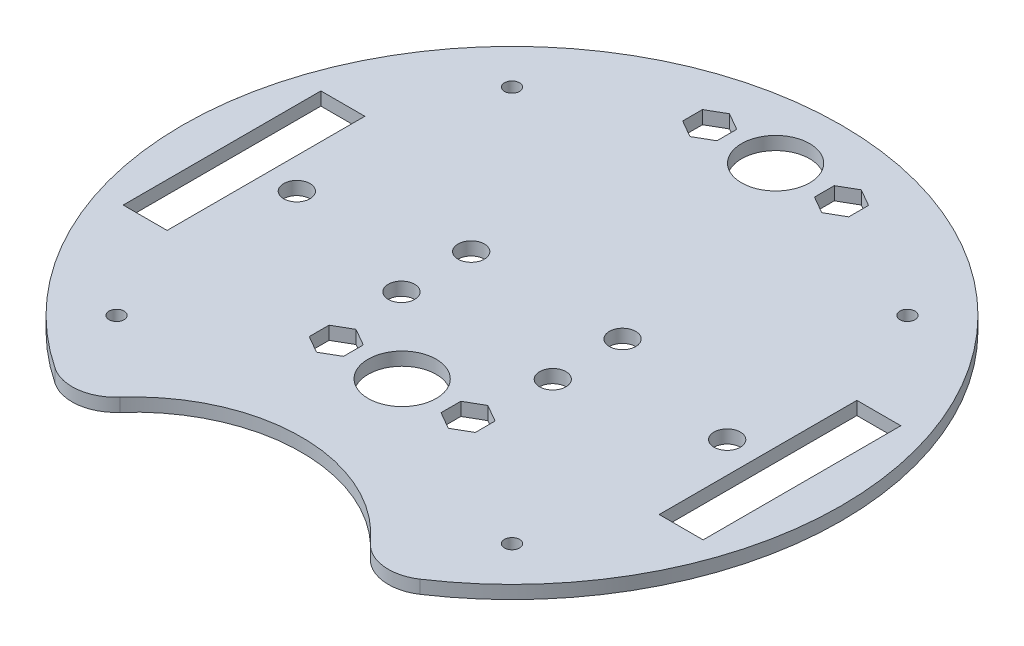
from build123d import *

# Parameters (mm, degrees)
SKETCH1_R           = 75
BOSS_EXTRUDE1_DEPTH = 3
SKETCH2_W           = 10
SKETCH2_H           = 45
CUT_EXTRUDE1_DEPTH  = 6.35
SKETCH3_R           = 7.75
CUT_EXTRUDE2_DEPTH  = 10
CUT_EXTRUDE3_DEPTH  = 10
FILLET2_R           = 10
SKETCH7_R           = 3
CUT_EXTRUDE5_DEPTH  = 3
CUT_EXTRUDE6_DEPTH  = 3
SKETCH8_R           = 1.7145
CUT_EXTRUDE7_DEPTH  = 10


with BuildPart() as part:
    # Sketch1 → Boss-Extrude1 (new body)
    with BuildSketch(Plane(origin=(0, 0, 0), x_dir=(1, 0, 0), z_dir=(0, 1, 0))):
        Circle(SKETCH1_R)
    extrude(amount=BOSS_EXTRUDE1_DEPTH)

    # Sketch2 → Cut-Extrude1 (cut)
    with BuildSketch(Plane(origin=(0, 3, 0), x_dir=(1, 0, 0), z_dir=(0, 1, 0))):
        with Locations((-61, 0)):
            Rectangle(SKETCH2_W, SKETCH2_H)
        with Locations((61, 0)):
            Rectangle(SKETCH2_W, SKETCH2_H)
    extrude(amount=-CUT_EXTRUDE1_DEPTH, mode=Mode.SUBTRACT)

    # Sketch3 → Cut-Extrude2 (cut)
    with BuildSketch(Plane(origin=(0, 3, 0), x_dir=(1, 0, 0), z_dir=(0, 1, 0))):
        with Locations((0, -25)):
            Circle(SKETCH3_R)
        with Locations((0, 60)):
            Circle(SKETCH3_R)
    extrude(amount=-CUT_EXTRUDE2_DEPTH, mode=Mode.SUBTRACT)

    # Sketch4 → Cut-Extrude3 (cut)
    with BuildSketch(Plane(origin=(0, 3, 0), x_dir=(1, 0, 0), z_dir=(0, 1, 0))):
        with BuildLine():
            ThreePointArc((-33.160552015, -67.270928268), (0, -47.932265908), (33.160552015, -67.270928268))
            ThreePointArc((33.160552015, -67.270928268), (0, -75), (-33.160552015, -67.270928268))
        make_face()
    extrude(amount=-CUT_EXTRUDE3_DEPTH, mode=Mode.SUBTRACT)

    # Fillet2
    fillet2_edges = [part.edges().sort_by_distance(p)[0] for p in [
        (-33.160552015, 1.5, 67.270928268),
        (33.160552015, 1.5, 67.270928268),
    ]]
    fillet(fillet2_edges, radius=FILLET2_R)

    # Sketch7 → Cut-Extrude5 (cut)
    with BuildSketch(Plane(origin=(0, 3, 0), x_dir=(1, 0, 0), z_dir=(0, 1, 0))):
        with Locations((-48.975, 0)):
            Circle(SKETCH7_R)
        with Locations((-17.225, -7.9375)):
            Circle(SKETCH7_R)
        with Locations((-17.225, 7.9375)):
            Circle(SKETCH7_R)
        with Locations((17.225, 7.9375)):
            Circle(SKETCH7_R)
        with Locations((17.225, -7.9375)):
            Circle(SKETCH7_R)
        with Locations((48.975, 0)):
            Circle(SKETCH7_R)
    extrude(amount=-CUT_EXTRUDE5_DEPTH, mode=Mode.SUBTRACT)

    # Sketch6 → Cut-Extrude6 (cut)
    with BuildSketch(Plane(origin=(0, 3, 0), x_dir=(1, 0, 0), z_dir=(0, 1, 0))):
        Polygon((-15, 64.502061929), (-18.8989, 62.251030965), (-18.8989, 57.748969035), (-15, 55.497938071), (-11.1011, 57.748969035), (-11.1011, 62.251030965), align=None)
        Polygon((15, 64.502061929), (11.1011, 62.251030965), (11.1011, 57.748969035), (15, 55.497938071), (18.8989, 57.748969035), (18.8989, 62.251030965), align=None)
        Polygon((-15, -20.497938071), (-18.8989, -22.748969035), (-18.8989, -27.251030965), (-15, -29.502061929), (-11.1011, -27.251030965), (-11.1011, -22.748969035), align=None)
        Polygon((15, -20.497938071), (11.1011, -22.748969035), (11.1011, -27.251030965), (15, -29.502061929), (18.8989, -27.251030965), (18.8989, -22.748969035), align=None)
    extrude(amount=-CUT_EXTRUDE6_DEPTH, mode=Mode.SUBTRACT)

    # Sketch8 → Cut-Extrude7 (cut)
    with BuildSketch(Plane(origin=(0, 0, 0), x_dir=(-1, 0, 0), z_dir=(0, -1, 0))):
        with Locations((45, -45)):
            Circle(SKETCH8_R)
        with Locations((-45, -45)):
            Circle(SKETCH8_R)
        with Locations((-45, 45)):
            Circle(SKETCH8_R)
        with Locations((45, 45)):
            Circle(SKETCH8_R)
    extrude(amount=-CUT_EXTRUDE7_DEPTH, mode=Mode.SUBTRACT)


solid = part.part
